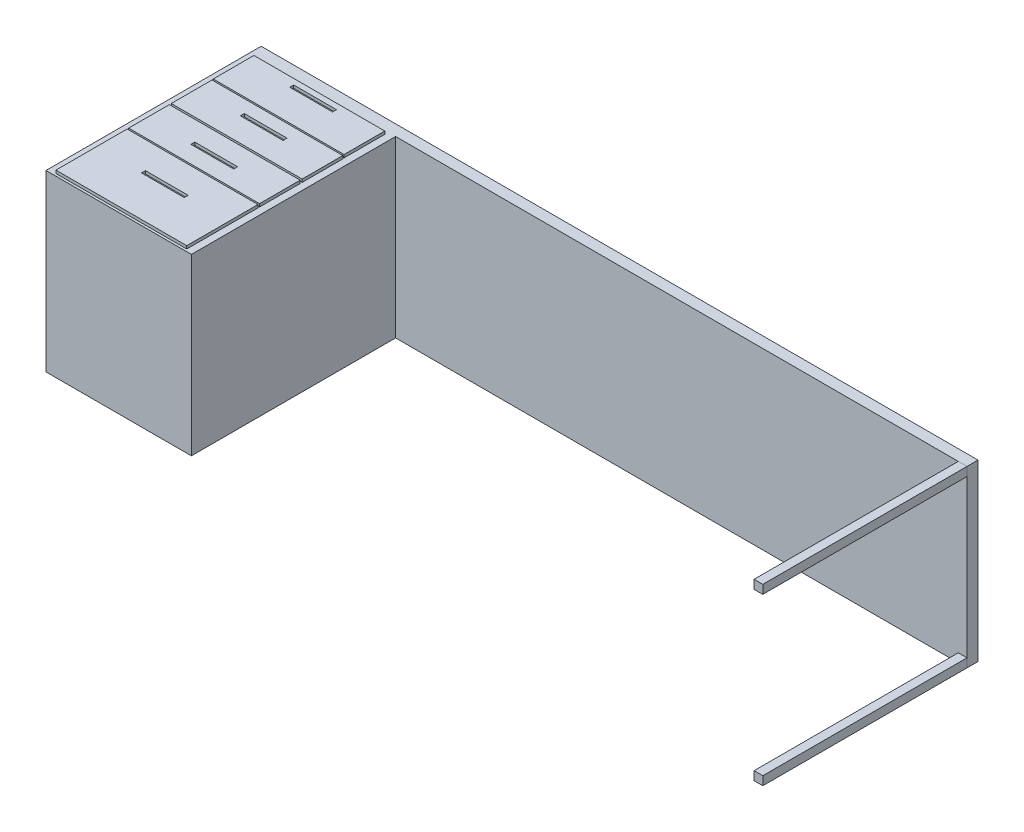
from build123d import *

# Parameters (mm, degrees)
BOSS_EXTRUDE1_DEPTH   = 600
SKETCH2_W             = 450
SKETCH2_H             = 140
SKETCH2_W_2           = 146.91343935
SKETCH2_H_2           = 13.581682478
SKETCH2_H_3           = 245
BOSS_EXTRUDE2_DEPTH   = 10
SKETCH3_W             = 30
SKETCH3_H             = 30
BOSS_EXTRUDE3_DEPTH   = 702.263166
BOSS_EXTRUDE3_2_DEPTH = 702.263166


with BuildPart() as part:
    # Sketch1 → Boss-Extrude1 (new body)
    with BuildSketch(Plane(origin=(0, 0, 0), x_dir=(1, 0, 0), z_dir=(0, 1, 0))):
        Polygon((-0.948488695, 0), (-0.948488695, 740), (2464.051511305, 740), (2464.051511305, 702.263165655), (1965, 702.263165655), (499.051511305, 702.263165655), (499.051511305, 0), align=None)
    extrude(amount=BOSS_EXTRUDE1_DEPTH)

    # Sketch2 → Boss-Extrude2 (add)
    with BuildSketch(Plane(origin=(0, 600, 0), x_dir=(1, 0, 0), z_dir=(0, 1, 0))):
        with Locations((249.05278621, 620)):
            Rectangle(SKETCH2_W, SKETCH2_H)
        with Locations((253.905576666, 663.689083521)):
            Rectangle(SKETCH2_W_2, SKETCH2_H_2, mode=Mode.SUBTRACT)
        with Locations((250.001274905, 474.789512045)):
            Rectangle(SKETCH2_W, SKETCH2_H)
        with Locations((253.905576666, 493.689083521)):
            Rectangle(SKETCH2_W_2, SKETCH2_H_2, mode=Mode.SUBTRACT)
        with Locations((250.001274905, 328.246947066)):
            Rectangle(SKETCH2_W, SKETCH2_H)
        with Locations((253.905576666, 323.689083521)):
            Rectangle(SKETCH2_W_2, SKETCH2_H_2, mode=Mode.SUBTRACT)
        with Locations((250.001274905, 130.536459111)):
            Rectangle(SKETCH2_W, SKETCH2_H_3)
        with Locations((253.905576666, 153.689083521)):
            Rectangle(SKETCH2_W_2, SKETCH2_H_2, mode=Mode.SUBTRACT)
    extrude(amount=BOSS_EXTRUDE2_DEPTH)


with BuildPart() as body_2:
    # Sketch3 → Boss-Extrude3 (new body)
    with BuildSketch(Plane.XY.offset(-702.263165655)):
        with Locations((2449.051511305, 15)):
            Rectangle(SKETCH3_W, SKETCH3_H)
    extrude(amount=BOSS_EXTRUDE3_DEPTH)


with BuildPart() as body_3:
    # Sketch3 → Boss-Extrude3 2 (new body)
    with BuildSketch(Plane.XY.offset(-702.263165655)):
        with Locations((2449.051511305, 585)):
            Rectangle(SKETCH3_W, SKETCH3_H)
    extrude(amount=BOSS_EXTRUDE3_2_DEPTH)


solid = Compound([part.part, body_2.part, body_3.part])
